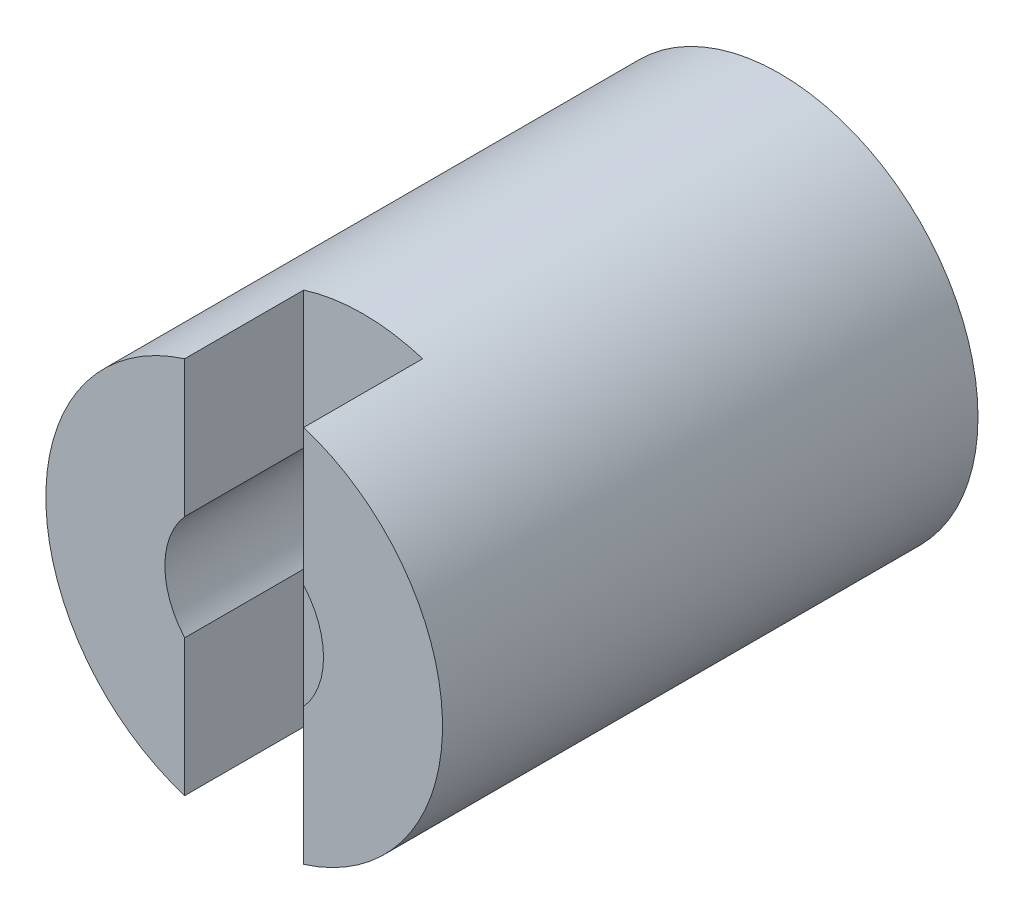
from build123d import *

# Parameters (mm, degrees)
SKETCH1_R           = 10
BOSS_EXTRUDE1_DEPTH = 27
SKETCH2_R           = 4
CUT_EXTRUDE1_DEPTH  = 140
SKETCH3_R           = 6
CUT_EXTRUDE2_DEPTH  = 15
SKETCH4_W           = 6
SKETCH4_H           = 6
CUT_EXTRUDE3_DEPTH  = 15
SKETCH5_W           = 3.5796646
SKETCH5_H           = 5
CUT_EXTRUDE4_DEPTH  = 15


with BuildPart() as part:
    # Sketch1 → Boss-Extrude1 (new body)
    with BuildSketch(Plane.XY):
        Circle(SKETCH1_R)
    extrude(amount=BOSS_EXTRUDE1_DEPTH)

    # Sketch2 → Cut-Extrude1 (cut)
    with BuildSketch(Plane.XY.offset(27)):
        Circle(SKETCH2_R)
    extrude(amount=-CUT_EXTRUDE1_DEPTH, mode=Mode.SUBTRACT)

    # Sketch3 → Cut-Extrude2 (cut)
    with BuildSketch(Plane(origin=(0, 0, 0), x_dir=(-1, 0, 0), z_dir=(0, 0, -1))):
        Circle(SKETCH3_R)
    extrude(amount=-CUT_EXTRUDE2_DEPTH, mode=Mode.SUBTRACT)

    # Sketch4 → Cut-Extrude3 (cut, symmetric)
    with BuildSketch(Plane(origin=(0, 0, 0), x_dir=(1, 0, 0), z_dir=(0, 1, 0))):
        with Locations((0, -24)):
            Rectangle(SKETCH4_W, SKETCH4_H)
    extrude(amount=CUT_EXTRUDE3_DEPTH, both=True, mode=Mode.SUBTRACT)

    # Sketch5 → Cut-Extrude4 (cut)
    with BuildSketch(Plane(origin=(0, 0, 0), x_dir=(-1, 0, 0), z_dir=(0, 0, -1))):
        with Locations((5.7101677, 0)):
            Rectangle(SKETCH5_W, SKETCH5_H)
    extrude(amount=-CUT_EXTRUDE4_DEPTH, mode=Mode.SUBTRACT)


solid = part.part
